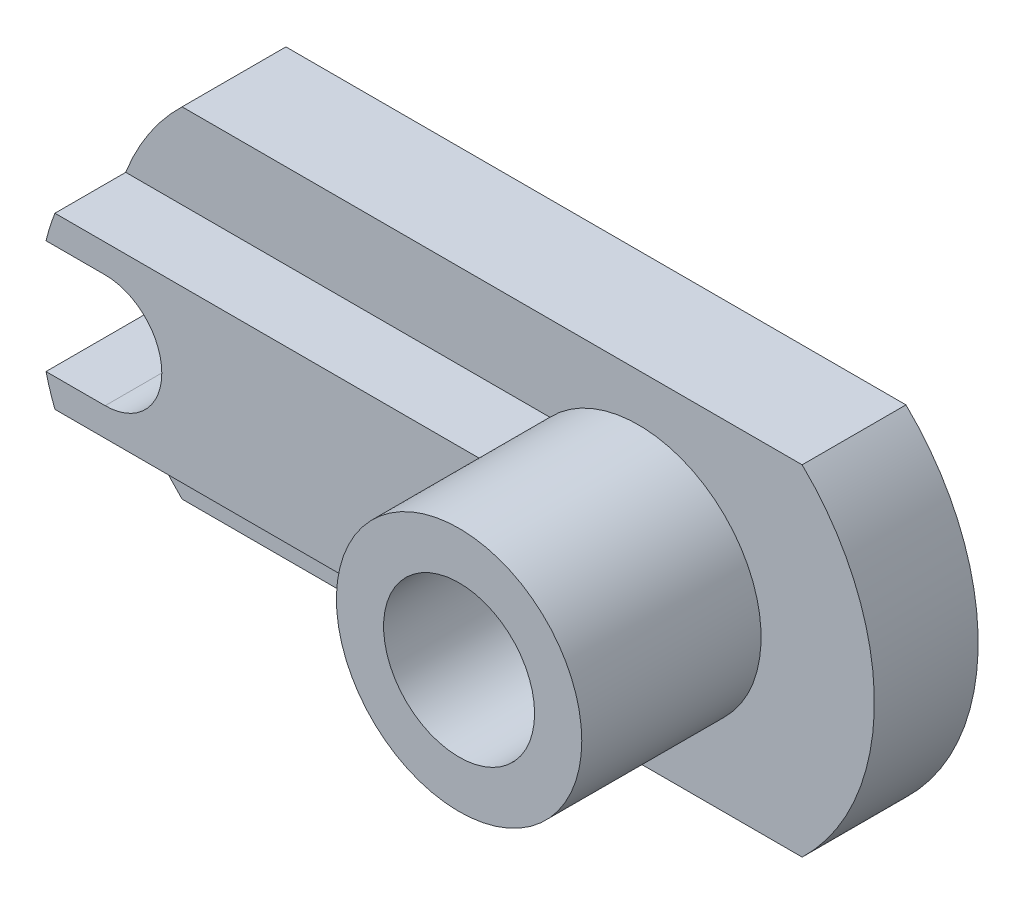
from build123d import *

# Parameters (mm, degrees)
BOSS_EXTRUDE1_DEPTH = 11
BOSS_EXTRUDE2_DEPTH = 7.5
SKETCH2_3_R         = 13
SKETCH2_3_R_2       = 8
BOSS_EXTRUDE3_DEPTH = 19
SKETCH8_R           = 8
CUT_EXTRUDE1_DEPTH  = 19


with BuildPart() as part:
    # Sketch1 → Boss-Extrude1 (new body)
    with BuildSketch(Plane.XY):
        with BuildLine():
            Line((-32.849351573, -18), (32.849351573, -18))
            ThreePointArc((32.849351573, -18), (40.5, 0), (32.849351573, 18))
            Line((32.849351573, 18), (-32.849351573, 18))
            ThreePointArc((-32.849351573, 18), (-37.157065859, 12.488854966), (-39.769322199, 6))
            Line((-39.769322199, 6), (-33.5, 6))
            ThreePointArc((-33.5, 6), (-27.5, 0), (-33.5, -6))
            Line((-33.5, -6), (-39.769322199, -6))
            ThreePointArc((-39.769322199, -6), (-37.157065859, -12.488854966), (-32.849351573, -18))
        make_face()
    extrude(amount=-BOSS_EXTRUDE1_DEPTH)

    # Sketch2 → Boss-Extrude2 (add)
    with BuildSketch(Plane.XY):
        with BuildLine():
            ThreePointArc((-39.769322199, -6), (-39.343793753, -7.514885194), (-38.823807579, -9))
            Line((-38.823807579, -9), (6.11916848, -9))
            ThreePointArc((6.11916848, -9), (2.5, 0), (6.11916848, 9))
            Line((6.11916848, 9), (-38.823807579, 9))
            ThreePointArc((-38.823807579, 9), (-39.343793753, 7.514885194), (-39.769322199, 6))
            Line((-39.769322199, 6), (-33.5, 6))
            ThreePointArc((-33.5, 6), (-27.5, 0), (-33.5, -6))
            Line((-33.5, -6), (-39.769322199, -6))
        make_face()
    extrude(amount=BOSS_EXTRUDE2_DEPTH)

    # Sketch2_3 → Boss-Extrude3 (add)
    with BuildSketch(Plane.XY):
        with Locations((15.5, 0)):
            Circle(SKETCH2_3_R)
        with Locations((15.5, 0)):
            Circle(SKETCH2_3_R_2, mode=Mode.SUBTRACT)
    extrude(amount=BOSS_EXTRUDE3_DEPTH)

    # Sketch8 → Cut-Extrude1 (cut)
    with BuildSketch(Plane.XY):
        with Locations((15.5, 0)):
            Circle(SKETCH8_R)
    extrude(amount=-CUT_EXTRUDE1_DEPTH, mode=Mode.SUBTRACT)


solid = part.part
